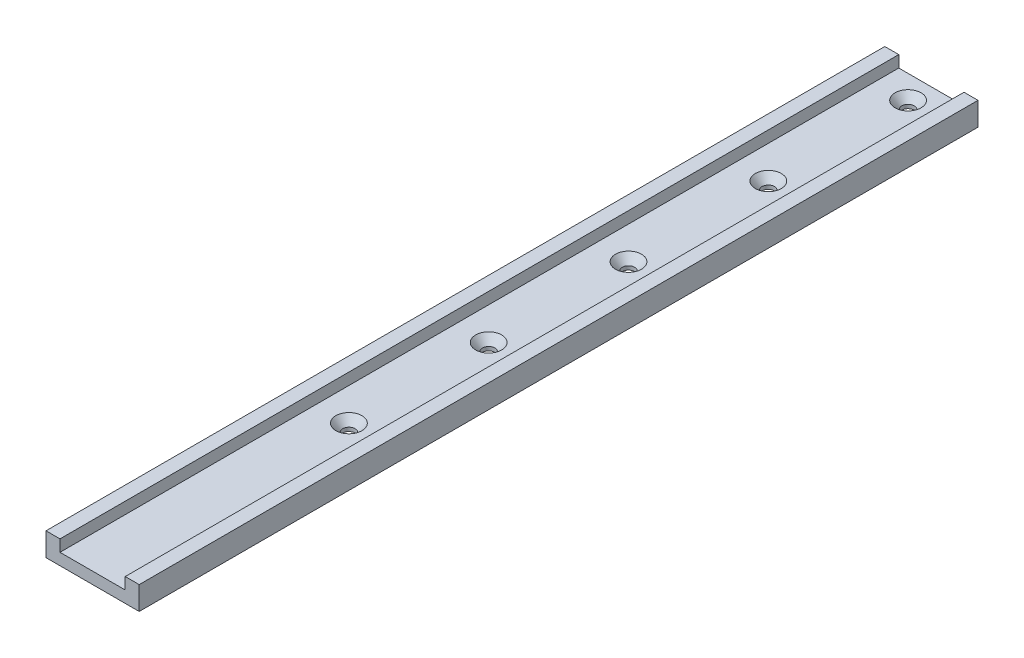
from build123d import *

# Parameters (mm, degrees)
BOSS_EXTRUDE1_DEPTH                           = 457.2
CSK_FOR_1_4_FLAT_HEAD_MACHINE_SCREW3_AT_COUNT = 2
CSK_FOR_1_4_FLAT_HEAD_MACHINE_SCREW3_AT_PITCH = 76.2
CSK_FOR_1_4_FLAT_HEAD_MACHINE_SCREW3_2_COUNT  = 2
CSK_FOR_1_4_FLAT_HEAD_MACHINE_SCREW3_2_PITCH  = 152.4
CSK_FOR_1_4_FLAT_HEAD_MACHINE_SCREW3_3_COUNT  = 2
CSK_FOR_1_4_FLAT_HEAD_MACHINE_SCREW3_3_PITCH  = 228.6
CSK_FOR_1_4_FLAT_HEAD_MACHINE_SCREW3_4_COUNT  = 2
CSK_FOR_1_4_FLAT_HEAD_MACHINE_SCREW3_4_PITCH  = 304.8


with BuildPart() as part:
    # Sketch → Boss-Extrude1 (new body)
    with BuildSketch(Plane.XY):
        Polygon((-17.78, 6.35), (-17.78, 12.7), (-25.4, 12.7), (-25.4, 0), (25.4, 0), (25.4, 12.7), (17.78, 12.7), (17.78, 6.35), align=None)
    extrude(amount=BOSS_EXTRUDE1_DEPTH)

    # Sketch4 → CSK for 1/4 Flat Head Machine Screw3 (revolve, cut)
    with BuildSketch(Plane(origin=(0, 6.35, 12.7), x_dir=(0, 0, 1), z_dir=(1, 0, 0))):
        Polygon((0, 0), (0, 6.35), (3.3782, 6.35), (3.3782, 4.28291499), (7.1012812, 0), align=None)
    csk_for_1_4_flat_head_machine_screw3 = revolve(axis=Axis((0, 12.7, 12.7), (0, -1, 0)), mode=Mode.SUBTRACT)

    # CSK for 1/4 Flat Head Machine Screw3 at: CSK for 1/4 Flat Head Machine Screw3 ×2
    with Locations(*[(0, 0, i * CSK_FOR_1_4_FLAT_HEAD_MACHINE_SCREW3_AT_PITCH) for i in range(1, CSK_FOR_1_4_FLAT_HEAD_MACHINE_SCREW3_AT_COUNT)]):
        add(csk_for_1_4_flat_head_machine_screw3, mode=Mode.SUBTRACT)

    # CSK for 1_4 Flat Head Machine Screw3 2: CSK for 1/4 Flat Head Machine Screw3 ×2
    with Locations(*[(0, 0, i * CSK_FOR_1_4_FLAT_HEAD_MACHINE_SCREW3_2_PITCH) for i in range(1, CSK_FOR_1_4_FLAT_HEAD_MACHINE_SCREW3_2_COUNT)]):
        add(csk_for_1_4_flat_head_machine_screw3, mode=Mode.SUBTRACT)

    # CSK for 1_4 Flat Head Machine Screw3 3: CSK for 1/4 Flat Head Machine Screw3 ×2
    with Locations(*[(0, 0, i * CSK_FOR_1_4_FLAT_HEAD_MACHINE_SCREW3_3_PITCH) for i in range(1, CSK_FOR_1_4_FLAT_HEAD_MACHINE_SCREW3_3_COUNT)]):
        add(csk_for_1_4_flat_head_machine_screw3, mode=Mode.SUBTRACT)

    # CSK for 1_4 Flat Head Machine Screw3 4: CSK for 1/4 Flat Head Machine Screw3 ×2
    with Locations(*[(0, 0, i * CSK_FOR_1_4_FLAT_HEAD_MACHINE_SCREW3_4_PITCH) for i in range(1, CSK_FOR_1_4_FLAT_HEAD_MACHINE_SCREW3_4_COUNT)]):
        add(csk_for_1_4_flat_head_machine_screw3, mode=Mode.SUBTRACT)


solid = part.part
